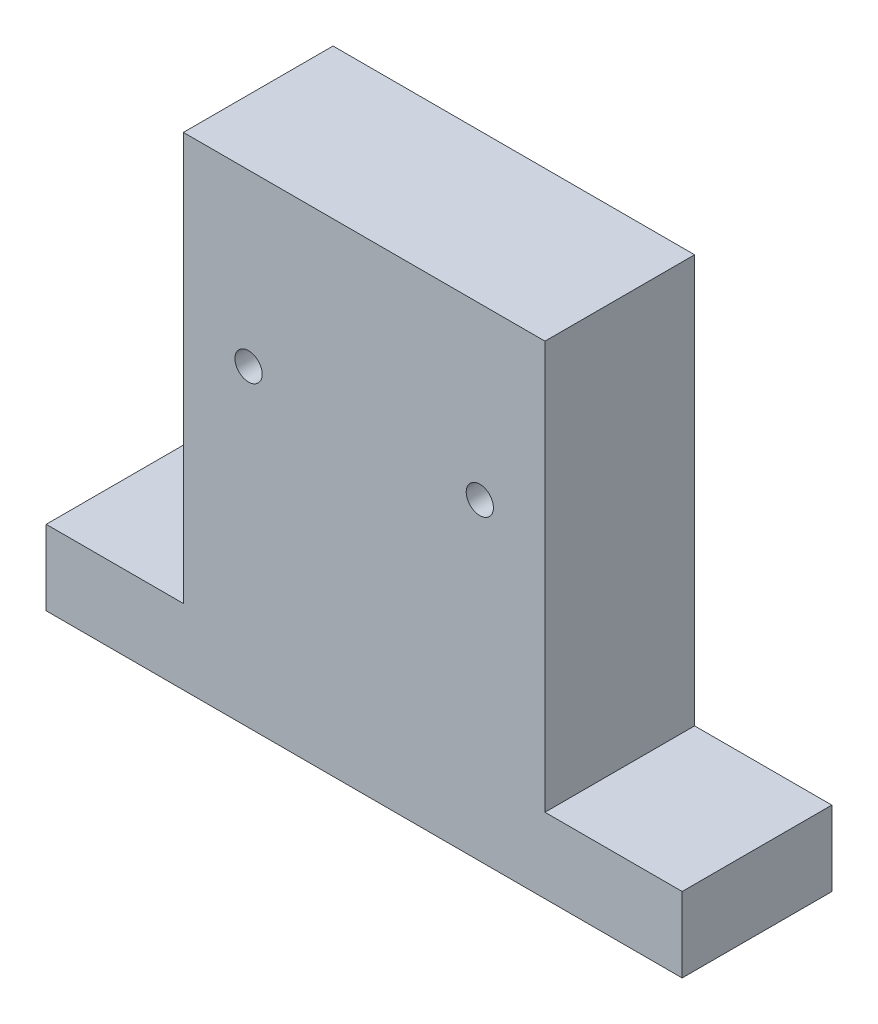
from build123d import *

# Parameters (mm, degrees)
SKETCH1_R           = 4
BOSS_EXTRUDE1_DEPTH = 44


with BuildPart() as part:
    # Sketch1 → Boss-Extrude1 (new body)
    with BuildSketch(Plane.XY):
        Polygon((46.673707227, -46.404256771), (87.016122023, -46.404256771), (87.016122023, -68.43728916), (-99.983877977, -68.43728916), (-99.983877977, -46.404256771), (-59.641463181, -46.404256771), (-59.641463181, 73.56271084), (46.673707227, 73.56271084), align=None)
        with Locations((-40.483877977, 23.56271084)):
            Circle(SKETCH1_R, mode=Mode.SUBTRACT)
        with Locations((27.516122023, 23.56271084)):
            Circle(SKETCH1_R, mode=Mode.SUBTRACT)
    extrude(amount=BOSS_EXTRUDE1_DEPTH)


solid = part.part
